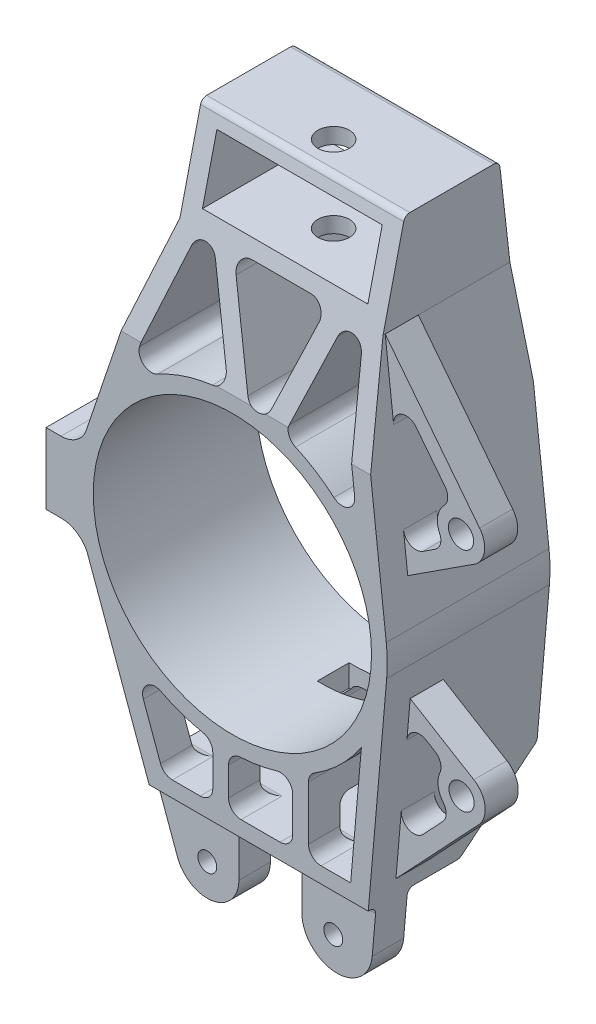
from build123d import *

# Parameters (mm, degrees)
SKETCH1_R               = 3
SKETCH1_R_2             = 44.17744667
SKETCH1_W               = 52.5
SKETCH1_H               = 19.5
BOSS_EXTRUDE1_DEPTH     = 25.835
CUT_EXTRUDE1_DEPTH      = 125.461402053
CUT_EXTRUDE1_DEPTH_BACK = 125.461402053
FILLET1_R               = 2
SKETCH5_R               = 4
BOSS_EXTRUDE2_DEPTH     = 10.5
BOSS_EXTRUDE3_DEPTH     = 26.37
CUT_EXTRUDE2_REACH      = 175.948
CUT_EXTRUDE2_END_RADIUS = 49.17744667
SKETCH7_R               = 2.75
CUT_EXTRUDE4_REACH      = 222.707
SKETCH10_R              = 5
CUT_EXTRUDE5_START      = -32.848332
CUT_EXTRUDE5_DEPTH      = 61.004944
SKETCH12_W              = 20.384350052
SKETCH12_H              = 10.085001151
CUT_EXTRUDE6_DEPTH      = 51.17744667


with BuildPart() as part:
    # Sketch1 → Boss-Extrude1 (new, symmetric)
    with BuildSketch(Plane.XY):
        with BuildLine():
            Line((-24.333061453, 81.876712624), (-46.608830439, 15.685604423))
            ThreePointArc((-46.608830439, 15.685604423), (-49.173776541, -0.600800907), (-46.211683745, -16.819677359))
            Line((-46.211683745, -16.819677359), (-19.916030232, -89.066391616))
            ThreePointArc((-19.916030232, -89.066391616), (-8.753130377, -95.528899343), (-0.427073715, -85.67744667))
            Line((-0.427073715, -85.67744667), (-0.427073715, -71.17744667))
            Line((-0.427073715, -71.17744667), (19.572926285, -71.17744667))
            Line((19.572926285, -71.17744667), (19.572926285, -85.67744667))
            ThreePointArc((19.572926285, -85.67744667), (30.838296467, -95.676822157), (41.890099306, -85.441895218))
            Line((41.890099306, -85.441895218), (48.990311639, -4.286096891))
            ThreePointArc((48.990311639, -4.286096891), (49.173233519, 0.643712888), (48.861326946, 5.567045008))
            Line((48.861326946, 5.567045008), (40.166938547, 81.876712624))
            Line((40.166938547, 81.876712624), (40.166938547, 111.376712624))
            Line((40.166938547, 111.376712624), (-24.333061453, 111.376712624))
            Line((-24.333061453, 111.376712624), (-24.333061453, 81.876712624))
        make_face()
        with Locations((-10.474465133, -85.629942955)):
            Circle(SKETCH1_R, mode=Mode.SUBTRACT)
        with Locations((29.525534867, -85.629942955)):
            Circle(SKETCH1_R, mode=Mode.SUBTRACT)
        Circle(SKETCH1_R_2, mode=Mode.SUBTRACT)
        with BuildLine():
            Line((-1.489783191, 81.876712624), (17.323660285, 81.876712624))
            ThreePointArc((17.323660285, 81.876712624), (20.595092, 80.178393429), (21.088556078, 76.525579889))
            Line((21.088556078, 76.525579889), (11.974377491, 51.129161219))
            ThreePointArc((11.974377491, 51.129161219), (8.249997752, 48.480499153), (4.472728318, 51.053173015))
            Line((4.472728318, 51.053173015), (-5.226536572, 76.449591685))
            ThreePointArc((-5.226536572, 76.449591685), (-4.784360839, 80.145138977), (-1.489783191, 81.876712624))
        make_face(mode=Mode.SUBTRACT)
        with Locations((7.916938547, 96.626712624)):
            Rectangle(SKETCH1_W, SKETCH1_H, mode=Mode.SUBTRACT)
        with BuildLine():
            Line((34.927451287, 74.861073276), (38.829349223, 40.614554616))
            ThreePointArc((38.829349223, 40.614554616), (36.718951762, 36.62254493), (32.233268993, 37.140781239))
            ThreePointArc((32.233268993, 37.140781239), (26.426414079, 41.473677194), (20.045955076, 44.906357524))
            ThreePointArc((20.045955076, 44.906357524), (17.997201864, 46.989529636), (17.911559151, 49.91008799))
            Line((17.911559151, 49.91008799), (27.188268072, 75.759393156))
            ThreePointArc((27.188268072, 75.759393156), (31.414364326, 78.381583228), (34.927451287, 74.861073276))
        make_face(mode=Mode.SUBTRACT)
        with BuildLine():
            Line((-12.022760406, 77.427653422), (-3.135959437, 54.158578845))
            ThreePointArc((-3.135959437, 54.158578845), (-3.438154868, 50.681138006), (-6.355748333, 48.765005118))
            ThreePointArc((-6.355748333, 48.765005118), (-15.310652659, 46.733341162), (-23.731752898, 43.07232482))
            ThreePointArc((-23.731752898, 43.07232482), (-28.226410266, 43.50588442), (-29.453122193, 47.851583055))
            Line((-29.453122193, 47.851583055), (-19.550587426, 77.27636972))
            ThreePointArc((-19.550587426, 77.27636972), (-15.839883944, 79.999724981), (-12.022760406, 77.427653422))
        make_face(mode=Mode.SUBTRACT)
        with BuildLine():
            Line((-28.275211733, -48.556902797), (-22.819798581, -63.545527244))
            ThreePointArc((-22.819798581, -63.545527244), (-21.355333844, -65.454054848), (-19.061028098, -66.17744667))
            Line((-19.061028098, -66.17744667), (-10.227738023, -66.17744667))
            ThreePointArc((-10.227738023, -66.17744667), (-7.399310898, -65.005873795), (-6.227738023, -62.17744667))
            Line((-6.227738023, -62.17744667), (-6.227738023, -52.184616596))
            ThreePointArc((-6.227738023, -52.184616596), (-7.139266231, -49.642699605), (-9.458409019, -48.259297134))
            ThreePointArc((-9.458409019, -48.259297134), (-16.230589371, -46.421861549), (-22.672318014, -43.639285705))
            ThreePointArc((-22.672318014, -43.639285705), (-27.155040875, -44.182530153), (-28.275211733, -48.556902797))
        make_face(mode=Mode.SUBTRACT)
        with BuildLine():
            Line((24.156612029, -45.111484496), (24.156612029, -62.17744667))
            ThreePointArc((24.156612029, -62.17744667), (25.328184905, -65.005873795), (28.156612029, -66.17744667))
            Line((28.156612029, -66.17744667), (37.552601137, -66.17744667))
            Line((37.552601137, -66.17744667), (40.961501413, -27.213538231))
            ThreePointArc((40.961501413, -27.213538231), (34.276118097, -35.264273553), (26.038675664, -41.718205027))
            ThreePointArc((26.038675664, -41.718205027), (24.658630793, -43.171348606), (24.156612029, -45.111484496))
        make_face(mode=Mode.SUBTRACT)
        with BuildLine():
            Line((-1.227738023, -53.105135325), (-1.227738023, -62.17744667))
            ThreePointArc((-1.227738023, -62.17744667), (-0.056165148, -65.005873795), (2.772261977, -66.17744667))
            Line((2.772261977, -66.17744667), (15.156612029, -66.17744667))
            ThreePointArc((15.156612029, -66.17744667), (17.985039154, -65.005873795), (19.156612029, -62.17744667))
            Line((19.156612029, -62.17744667), (19.156612029, -50.971736739))
            ThreePointArc((19.156612029, -50.971736739), (17.548231477, -47.765468438), (14.016533821, -47.137649927))
            ThreePointArc((14.016533821, -47.137649927), (8.348617755, -48.463613594), (2.563732824, -49.110574574))
            ThreePointArc((2.563732824, -49.110574574), (-0.128954717, -50.351421162), (-1.227738023, -53.105135325))
        make_face(mode=Mode.SUBTRACT)
    extrude(amount=BOSS_EXTRUDE1_DEPTH, both=True)

    # Sketch3 → Cut-Extrude1 (cut, two sides)
    with BuildSketch(Plane(origin=(0, 0, 0), x_dir=(0, 0, -1), z_dir=(1, 0, 0))) as cut_extrude1_sk:
        with BuildLine():
            Line((25.835, -95.67744667), (25.835, -71.17744667))
            Line((25.835, -71.17744667), (25.335, -71.17744667))
            ThreePointArc((25.335, -71.17744667), (23.920786438, -71.763233108), (23.335, -73.17744667))
            Line((23.335, -73.17744667), (23.335, -95.67744667))
            Line((23.335, -95.67744667), (25.835, -95.67744667))
        make_face()
        with BuildLine():
            Line((13.335, -95.67744667), (13.335, -73.17744667))
            ThreePointArc((13.335, -73.17744667), (12.749213562, -71.763233108), (11.335, -71.17744667))
            Line((11.335, -71.17744667), (-2.354089758, -71.17744667))
            ThreePointArc((-2.354089758, -71.17744667), (-3.105579113, -71.030893122), (-3.746935037, -70.612710419))
            Line((-3.746935037, -70.612710419), (-25.835, -49.17744667))
            Line((-25.835, -49.17744667), (-25.835, -95.67744667))
            Line((-25.835, -95.67744667), (13.335, -95.67744667))
        make_face()
        with BuildLine():
            Line((-25.835, 49.17744667), (-18.95036426, 109.603119051))
            ThreePointArc((-18.95036426, 109.603119051), (-18.294983881, 110.868827374), (-16.963220549, 111.376712624))
            Line((-16.963220549, 111.376712624), (-25.835, 111.376712624))
            Line((-25.835, 111.376712624), (-25.835, 49.17744667))
        make_face()
        with BuildLine():
            Line((11.613591816, 109.833253612), (25.835, 49.17744667))
            Line((25.835, 49.17744667), (25.835, 111.376712624))
            Line((25.835, 111.376712624), (9.666396313, 111.376712624))
            ThreePointArc((9.666396313, 111.376712624), (10.908756571, 110.944048258), (11.613591816, 109.833253612))
        make_face()
    extrude(amount=CUT_EXTRUDE1_DEPTH, mode=Mode.SUBTRACT)
    extrude(cut_extrude1_sk.sketch, amount=-CUT_EXTRUDE1_DEPTH_BACK, mode=Mode.SUBTRACT)

    # Fillet1
    fillet1_edges = [part.edges().sort_by_distance(p)[0] for p in [
        (-31.241885551, -49.17744667, 25.835),
        (-2.787508752, -49.17744667, 25.835),
        (21.444104907, -49.17744667, 25.835),
        (42.05136793, -49.17744667, 25.835),
    ]]
    fillet(fillet1_edges, radius=FILLET1_R)

    # Sketch5 → Boss-Extrude2 (add)
    with BuildSketch(Plane.XY.offset(-6.985)):
        with BuildLine():
            Line((40.166938547, 81.876712624), (70.147675928, 43.503118685))
            ThreePointArc((70.147675928, 43.503118685), (71.694607282, 38.083802311), (69.030880587, 33.117259582))
            Line((69.030880587, 33.117259582), (47.32817385, 19.023357034))
            Line((47.32817385, 19.023357034), (45.963969857, 30.996821812))
            ThreePointArc((45.963969857, 30.996821812), (48.23198232, 27.831814086), (52.116813419, 28.094952396))
            Line((52.116813419, 28.094952396), (56.014564965, 30.626181846))
            ThreePointArc((56.014564965, 30.626181846), (57.683412554, 32.886567746), (57.453951939, 35.686879249))
            ThreePointArc((57.453951939, 35.686879249), (56.843274314, 40.140256162), (58.888701598, 44.142970281))
            ThreePointArc((58.888701598, 44.142970281), (60.029514526, 46.719915118), (59.188001317, 49.409516268))
            Line((59.188001317, 49.409516268), (49.982109578, 61.192520367))
            ThreePointArc((49.982109578, 61.192520367), (45.315472094, 62.432036481), (42.855779141, 58.27706161))
            Line((42.855779141, 58.27706161), (40.166938547, 81.876712624))
        make_face()
        with Locations((64.237595276, 38.88565762)):
            Circle(SKETCH5_R, mode=Mode.SUBTRACT)
        with BuildLine():
            Line((48.107618786, -14.37532237), (68.306121721, -26.60797056))
            ThreePointArc((68.306121721, -26.60797056), (71.851527954, -32.005335718), (69.888183856, -38.157305806))
            Line((69.888183856, -38.157305806), (43.575520163, -66.17744667))
            Line((43.575520163, -66.17744667), (45.286961109, -46.615587136))
            ThreePointArc((45.286961109, -46.615587136), (47.63841806, -50.615546816), (52.187614411, -49.702398531))
            Line((52.187614411, -49.702398531), (58.438302844, -43.046091423))
            ThreePointArc((58.438302844, -43.046091423), (59.520118213, -40.443828112), (58.617555575, -37.774094134))
            ThreePointArc((58.617555575, -37.774094134), (56.990310347, -34.041069305), (57.55372767, -30.007961034))
            ThreePointArc((57.55372767, -30.007961034), (57.705097835, -27.19385622), (55.963333585, -24.978375205))
            Line((55.963333585, -24.978375205), (53.11874132, -23.255628894))
            ThreePointArc((53.11874132, -23.255628894), (49.236894445, -23.109895816), (47.06185449, -26.328462964))
            Line((47.06185449, -26.328462964), (48.107618786, -14.37532237))
        make_face()
        with Locations((64.420919151, -33.023202511)):
            Circle(SKETCH5_R, mode=Mode.SUBTRACT)
    extrude(amount=-BOSS_EXTRUDE2_DEPTH)

    # Sketch6 → Boss-Extrude3 (add)
    with BuildSketch(Plane.XY.offset(0.535)):
        with BuildLine():
            Line((-59.173776541, 10.685604423), (-59.173776541, -11.819677359))
            Line((-59.173776541, -11.819677359), (-54.412210142, -11.819677359))
            ThreePointArc((-54.412210142, -11.819677359), (-49.609902541, -13.168250627), (-46.211683745, -16.819677359))
            ThreePointArc((-46.211683745, -16.819677359), (-49.173776541, -0.600800907), (-46.608830439, 15.685604423))
            ThreePointArc((-46.608830439, 15.685604423), (-49.778293473, 12.042835646), (-54.412210142, 10.685604423))
            Line((-54.412210142, 10.685604423), (-59.173776541, 10.685604423))
        make_face()
    extrude(amount=-BOSS_EXTRUDE3_DEPTH)

    # Cut-Extrude2: up to this cylinder (the profile starts outside it)
    cut_extrude2_end = Plane(origin=(0, 0, -11.983796), z_dir=(0, 0, -1)) * Cylinder(CUT_EXTRUDE2_END_RADIUS, 461.248485341, mode=Mode.PRIVATE)
    # Sketch7 → Cut-Extrude2 (cut, up to the surface)
    with BuildSketch(Plane.ZY.offset(59.173776541), mode=Mode.PRIVATE) as cut_extrude2_sk1:
        with Locations((-16.982592212, -0.372740434)):
            Circle(SKETCH7_R)
    cut_extrude2_tool1 = extrude(cut_extrude2_sk1.sketch, amount=-CUT_EXTRUDE2_REACH, mode=Mode.PRIVATE) - cut_extrude2_end
    add(cut_extrude2_tool1.solids().sort_by_distance((-59.173777, -0.37274, -16.982592))[0], mode=Mode.SUBTRACT)
    # Sketch7 → Cut-Extrude2 (cut, up to the surface)
    with BuildSketch(Plane.ZY.offset(59.173776541), mode=Mode.PRIVATE) as cut_extrude2_sk2:
        with Locations((-6.985, -0.153309453)):
            Circle(SKETCH7_R)
    cut_extrude2_tool2 = extrude(cut_extrude2_sk2.sketch, amount=-CUT_EXTRUDE2_REACH, mode=Mode.PRIVATE) - cut_extrude2_end
    add(cut_extrude2_tool2.solids().sort_by_distance((-59.173777, -0.153309, -6.985))[0], mode=Mode.SUBTRACT)

    # Cut-Extrude4: up to this face of the body (flat: up to its plane)
    cut_extrude4_end = Plane(part.part.faces().sort_by_distance((7.916938547, 81.876712624, 1.970542423))[0])
    # Sketch10 → Cut-Extrude4 (cut, up to the picked face)
    with BuildSketch(Plane(origin=(0, 111.376712624, 0), x_dir=(1, 0, 0), z_dir=(0, 1, 0)), mode=Mode.PRIVATE) as cut_extrude4_sk1:
        with Locations(Location((7.916938547, 1.613591816, 0), (0, 0, 180))):
            Circle(SKETCH10_R)
    cut_extrude4_tool1 = split(extrude(cut_extrude4_sk1.sketch, amount=-CUT_EXTRUDE4_REACH, mode=Mode.PRIVATE), bisect_by=cut_extrude4_end, keep=Keep.BOTH, mode=Mode.PRIVATE)
    add(cut_extrude4_tool1.solids().sort_by(Axis((7.916939, 111.376713, -1.613592), (0, -1, 0)))[0], mode=Mode.SUBTRACT)

    # Sketch11 → Cut-Extrude5 (cut)
    with BuildSketch(Plane(origin=(0, 0, 0), x_dir=(0, 0, -1), z_dir=(1, 0, 0)).offset(CUT_EXTRUDE5_START)):
        with BuildLine():
            Line((12.835, -66.17744667), (0.078640968, -66.17744667))
            ThreePointArc((0.078640968, -66.17744667), (-1.048593065, -65.957616348), (-2.01062695, -65.330342294))
            Line((-2.01062695, -65.330342294), (-8.855175283, -58.68808101))
            ThreePointArc((-8.855175283, -58.68808101), (-9.546077042, -55.407951353), (-6.765907364, -53.535185386))
            Line((-6.765907364, -53.535185386), (12.835, -53.535185386))
            ThreePointArc((12.835, -53.535185386), (14.956320344, -54.413865043), (15.835, -56.535185386))
            Line((15.835, -56.535185386), (15.835, -63.17744667))
            ThreePointArc((15.835, -63.17744667), (14.956320344, -65.298767014), (12.835, -66.17744667))
        make_face()
    extrude(amount=CUT_EXTRUDE5_DEPTH, mode=Mode.SUBTRACT)

    # Sketch12 → Cut-Extrude6 (cut)
    with BuildSketch(Plane(origin=(0, 0, 0), x_dir=(1, 0, 0), z_dir=(0, 1, 0))):
        with Locations((8.964437003, -7.396590334)):
            Rectangle(SKETCH12_W, SKETCH12_H)
    extrude(amount=-CUT_EXTRUDE6_DEPTH, mode=Mode.SUBTRACT)


with BuildPart() as body_2:
    # Mirror1: mirrored copy
    add(part.part.mirror(Plane.XY))


solid = body_2.part
